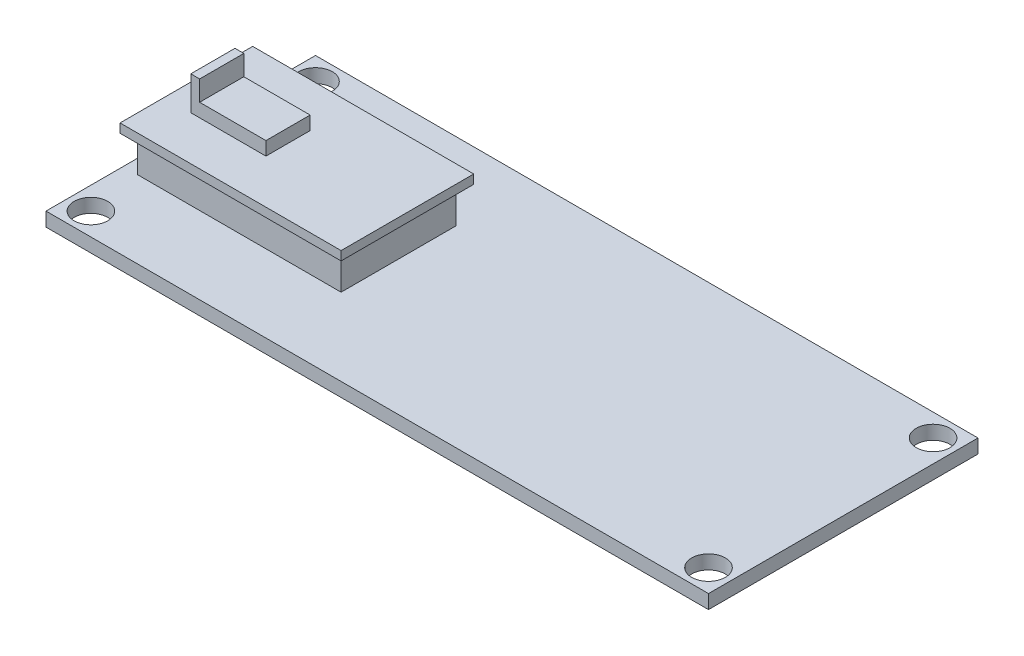
from build123d import *

# Parameters (mm, degrees)
SKETCH1_W           = 74.93
SKETCH1_H           = 30.48
SKETCH1_R           = 1.905
BOSS_EXTRUDE1_DEPTH = 1.5748
SKETCH2_W           = 25
SKETCH2_H           = 7.5
BOSS_EXTRUDE2_DEPTH = 5.08
CUT_EXTRUDE1_START  = -1.016
SKETCH3_W           = 25
SKETCH3_H           = 15
SKETCH3_W_2         = 23
SKETCH3_H_2         = 13
CUT_EXTRUDE1_DEPTH  = 4.064
SKETCH4_W           = 8.5
SKETCH4_H           = 5
BOSS_EXTRUDE3_DEPTH = 1.524
SKETCH5_W           = 1
SKETCH5_H           = 5
BOSS_EXTRUDE4_DEPTH = 2.286


with BuildPart() as part:
    # Sketch1 → Boss-Extrude1 (new body)
    with BuildSketch(Plane(origin=(0, 0, 0), x_dir=(1, 0, 0), z_dir=(0, 1, 0))):
        Rectangle(SKETCH1_W, SKETCH1_H)
        with Locations((-34.925, 12.7)):
            Circle(SKETCH1_R, mode=Mode.SUBTRACT)
        with Locations((34.925, 12.7)):
            Circle(SKETCH1_R, mode=Mode.SUBTRACT)
        with Locations((-34.925, -12.7)):
            Circle(SKETCH1_R, mode=Mode.SUBTRACT)
        with Locations((34.925, -12.7)):
            Circle(SKETCH1_R, mode=Mode.SUBTRACT)
    extrude(amount=-BOSS_EXTRUDE1_DEPTH)

    # Sketch2 → Boss-Extrude2 (add)
    with BuildSketch(Plane(origin=(0, 0, 0), x_dir=(1, 0, 0), z_dir=(0, 1, 0))):
        with Locations((-24.33, 3.75)):
            Rectangle(SKETCH2_W, SKETCH2_H)
        with Locations((-24.33, -3.75)):
            Rectangle(SKETCH2_W, SKETCH2_H)
    extrude(amount=BOSS_EXTRUDE2_DEPTH)

    # Sketch3 → Cut-Extrude1 (cut)
    with BuildSketch(Plane(origin=(0, 5.08, 0), x_dir=(1, 0, 0), z_dir=(0, 1, 0)).offset(CUT_EXTRUDE1_START)):
        with Locations((-24.33, 0)):
            Rectangle(SKETCH3_W, SKETCH3_H)
        with Locations((-24.33, 0)):
            Rectangle(SKETCH3_W_2, SKETCH3_H_2, mode=Mode.SUBTRACT)
    extrude(amount=-CUT_EXTRUDE1_DEPTH, mode=Mode.SUBTRACT)

    # Sketch4 → Boss-Extrude3 (add)
    with BuildSketch(Plane(origin=(0, 5.08, 0), x_dir=(1, 0, 0), z_dir=(0, 1, 0))):
        with Locations((-29.58, 0)):
            Rectangle(SKETCH4_W, SKETCH4_H)
    extrude(amount=BOSS_EXTRUDE3_DEPTH)

    # Sketch5 → Boss-Extrude4 (add)
    with BuildSketch(Plane(origin=(0, 6.604, 0), x_dir=(1, 0, 0), z_dir=(0, 1, 0))):
        with Locations((-33.33, 0)):
            Rectangle(SKETCH5_W, SKETCH5_H)
    extrude(amount=BOSS_EXTRUDE4_DEPTH)


solid = part.part
